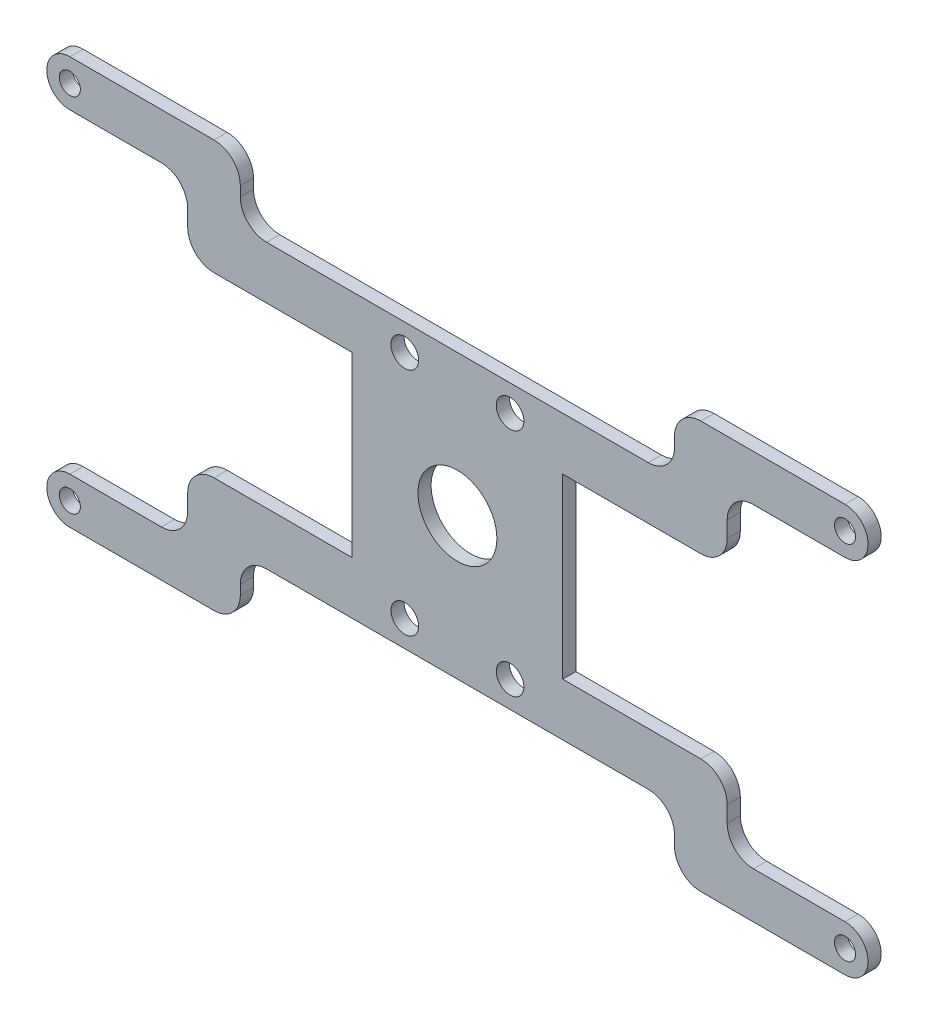
from build123d import *

# Parameters (mm, degrees)
SKETCH1_R           = 1.6
SKETCH1_R_2         = 2.1
BOSS_EXTRUDE3_DEPTH = 2
BOSS_EXTRUDE4_DEPTH = 2
SKETCH4_W           = 66
SKETCH4_H           = 16.340111315
SKETCH4_H_2         = 24.741581589
CUT_EXTRUDE3_DEPTH  = 14.5
FILLET1_R           = 4
SKETCH5_W           = 26
SKETCH5_H           = 27
SKETCH5_R           = 6
BOSS_EXTRUDE5_DEPTH = 2
SKETCH6_W           = 5
SKETCH6_H           = 27
CUT_EXTRUDE4_DEPTH  = 14.5


with BuildPart() as part:
    # Sketch1 → Boss-Extrude3 (new body)
    with BuildSketch(Plane.XY):
        with BuildLine():
            Line((0, 3.5), (37.911912125, 3.5))
            Line((37.911912125, 3.5), (37.911912125, 13.97107578))
            Line((37.911912125, 13.97107578), (37.911912125, 40.97107578))
            Line((37.911912125, 40.97107578), (37.911912125, 51.44215156))
            Line((37.911912125, 51.44215156), (0, 51.44215156))
            ThreePointArc((0, 51.44215156), (-3.5, 54.94215156), (0, 58.44215156))
            Line((0, 58.44215156), (45.911912125, 58.44215156))
            Line((45.911912125, 58.44215156), (45.911912125, 51.44215156))
            Line((45.911912125, 51.44215156), (45.911912125, 48.97107578))
            Line((45.911912125, 48.97107578), (50.911912125, 48.97107578))
            Line((50.911912125, 48.97107578), (66.911912125, 48.97107578))
            Line((66.911912125, 48.97107578), (71.911912125, 48.97107578))
            Line((71.911912125, 48.97107578), (71.911912125, 51.44215156))
            Line((71.911912125, 51.44215156), (71.911912125, 58.44215156))
            Line((71.911912125, 58.44215156), (117.82382425, 58.44215156))
            ThreePointArc((117.82382425, 58.44215156), (121.32382425, 54.94215156), (117.82382425, 51.44215156))
            Line((117.82382425, 51.44215156), (79.911912125, 51.44215156))
            Line((79.911912125, 51.44215156), (79.911912125, 40.97107578))
            Line((79.911912125, 40.97107578), (79.911912125, 13.97107578))
            Line((79.911912125, 13.97107578), (79.911912125, 3.5))
            Line((79.911912125, 3.5), (117.82382425, 3.5))
            ThreePointArc((117.82382425, 3.5), (121.32382425, 0), (117.82382425, -3.5))
            Line((117.82382425, -3.5), (71.911912125, -3.5))
            Line((71.911912125, -3.5), (71.911912125, 3.5))
            Line((71.911912125, 3.5), (71.911912125, 5.97107578))
            Line((71.911912125, 5.97107578), (66.911912125, 5.97107578))
            Line((66.911912125, 5.97107578), (50.911912125, 5.97107578))
            Line((50.911912125, 5.97107578), (45.911912125, 5.97107578))
            Line((45.911912125, 5.97107578), (45.911912125, 3.5))
            Line((45.911912125, 3.5), (45.911912125, -3.5))
            Line((45.911912125, -3.5), (0, -3.5))
            ThreePointArc((0, -3.5), (-3.5, 0), (0, 3.5))
        make_face()
        with Locations((0, 54.94215156)):
            Circle(SKETCH1_R, mode=Mode.SUBTRACT)
        with Locations((117.82382425, 54.94215156)):
            Circle(SKETCH1_R, mode=Mode.SUBTRACT)
        with Locations((117.82382425, 0)):
            Circle(SKETCH1_R, mode=Mode.SUBTRACT)
        Circle(SKETCH1_R, mode=Mode.SUBTRACT)
        with Locations((66.911912125, 44.97107578)):
            Circle(SKETCH1_R_2, mode=Mode.SUBTRACT)
        with Locations((66.911912125, 9.97107578)):
            Circle(SKETCH1_R_2, mode=Mode.SUBTRACT)
        with Locations((50.911912125, 9.97107578)):
            Circle(SKETCH1_R_2, mode=Mode.SUBTRACT)
        with Locations((50.911912125, 44.97107578)):
            Circle(SKETCH1_R_2, mode=Mode.SUBTRACT)
        Polygon((66.911912125, 40.97107578), (50.911912125, 40.97107578), (45.911912125, 40.97107578), (45.911912125, 27.47107578), (45.911912125, 13.97107578), (50.911912125, 13.97107578), (66.911912125, 13.97107578), (71.911912125, 13.97107578), (71.911912125, 27.47107578), (71.911912125, 40.97107578), align=None, mode=Mode.SUBTRACT)
    extrude(amount=BOSS_EXTRUDE3_DEPTH)

    # Sketch3 → Boss-Extrude4 (add)
    with BuildSketch(Plane.XY.offset(2)):
        Polygon((71.911912125, 13.97107578), (99.911912125, 13.97107578), (99.911912125, 3.5), (91.911912125, 3.5), (91.911912125, 5.97107578), (71.911912125, 5.97107578), align=None)
        Polygon((91.911912125, 51.44215156), (99.911912125, 51.44215156), (99.911912125, 40.97107578), (71.911912125, 40.97107578), (71.911912125, 48.97107578), (91.911912125, 48.97107578), align=None)
        Polygon((45.911912125, 40.97107578), (17.911912125, 40.97107578), (17.911912125, 51.44215156), (25.911912125, 51.44215156), (25.911912125, 48.97107578), (45.911912125, 48.97107578), align=None)
        Polygon((25.911912125, 3.5), (17.911912125, 3.5), (17.911912125, 13.97107578), (45.911912125, 13.97107578), (45.911912125, 5.97107578), (25.911912125, 5.97107578), align=None)
    extrude(amount=-BOSS_EXTRUDE4_DEPTH)

    # Sketch4 → Cut-Extrude3 (cut)
    with BuildSketch(Plane.XY.offset(2)):
        with Locations((58.911912125, 57.141131438)):
            Rectangle(SKETCH4_W, SKETCH4_H)
        with Locations((58.911912125, -6.399715014)):
            Rectangle(SKETCH4_W, SKETCH4_H_2)
    extrude(amount=-CUT_EXTRUDE3_DEPTH, mode=Mode.SUBTRACT)

    # Fillet1
    fillet1_edges = [part.edges().sort_by_distance(p)[0] for p in [
        (99.911912125, 13.97107578, 1),
        (99.911912125, 3.5, 1),
        (91.911912125, 5.97107578, 1),
        (91.911912125, 48.97107578, 1),
        (99.911912125, 51.44215156, 1),
        (99.911912125, 40.97107578, 1),
        (17.911912125, 40.97107578, 1),
        (17.911912125, 51.44215156, 1),
        (25.911912125, 48.97107578, 1),
        (25.911912125, 5.97107578, 1),
        (17.911912125, 3.5, 1),
        (17.911912125, 13.97107578, 1),
        (91.911912125, 58.44215156, 1),
        (25.911912125, 58.44215156, 1),
        (91.911912125, -3.5, 1),
        (25.911912125, -3.5, 1),
    ]]
    fillet(fillet1_edges, radius=FILLET1_R)

    # Sketch5 → Boss-Extrude5 (add)
    with BuildSketch(Plane.XY.offset(2)):
        with Locations((58.911912125, 27.47107578)):
            Rectangle(SKETCH5_W, SKETCH5_H)
        with Locations((58.911912125, 27.47107578)):
            Circle(SKETCH5_R, mode=Mode.SUBTRACT)
    extrude(amount=-BOSS_EXTRUDE5_DEPTH)

    # Sketch6 → Cut-Extrude4 (cut)
    with BuildSketch(Plane.XY.offset(2)):
        with Locations((40.411912125, 27.47107578)):
            Rectangle(SKETCH6_W, SKETCH6_H)
        with Locations((77.411912125, 27.47107578)):
            Rectangle(SKETCH6_W, SKETCH6_H)
    extrude(amount=-CUT_EXTRUDE4_DEPTH, mode=Mode.SUBTRACT)


solid = part.part
